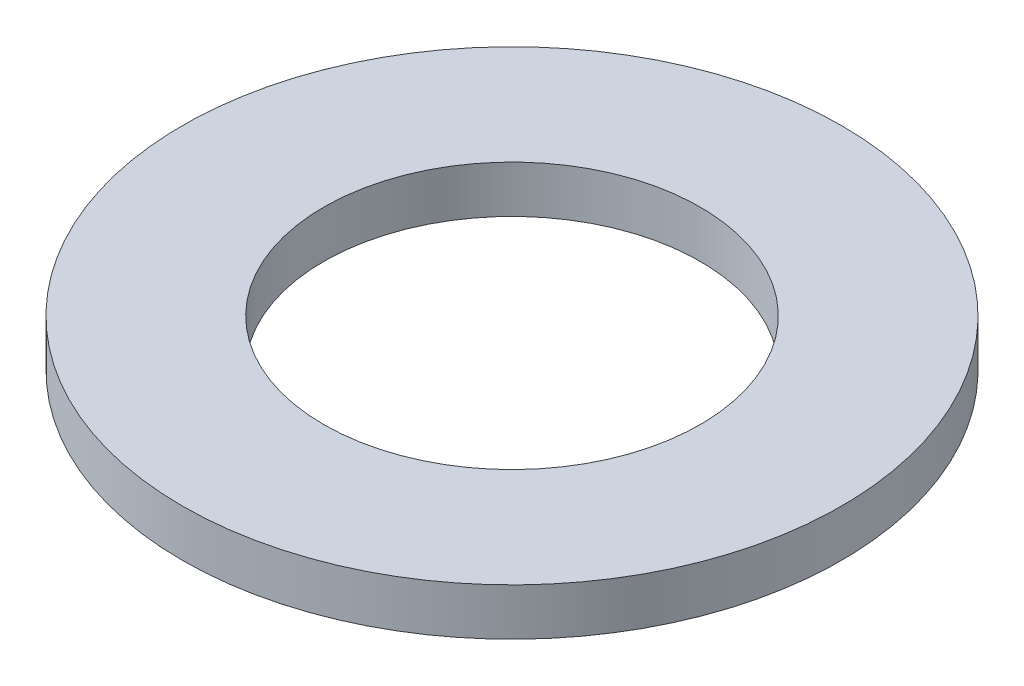
from build123d import *

# Parameters (mm, degrees)
SKETCH1_R           = 11.1125
SKETCH1_R_2         = 6.35
BOSS_EXTRUDE1_DEPTH = 1.5875


with BuildPart() as part:
    # Sketch1 → Boss-Extrude1 (new body)
    with BuildSketch(Plane(origin=(0, 0, 0), x_dir=(1, 0, 0), z_dir=(0, 1, 0))):
        Circle(SKETCH1_R)
        Circle(SKETCH1_R_2, mode=Mode.SUBTRACT)
    extrude(amount=BOSS_EXTRUDE1_DEPTH)


solid = part.part
